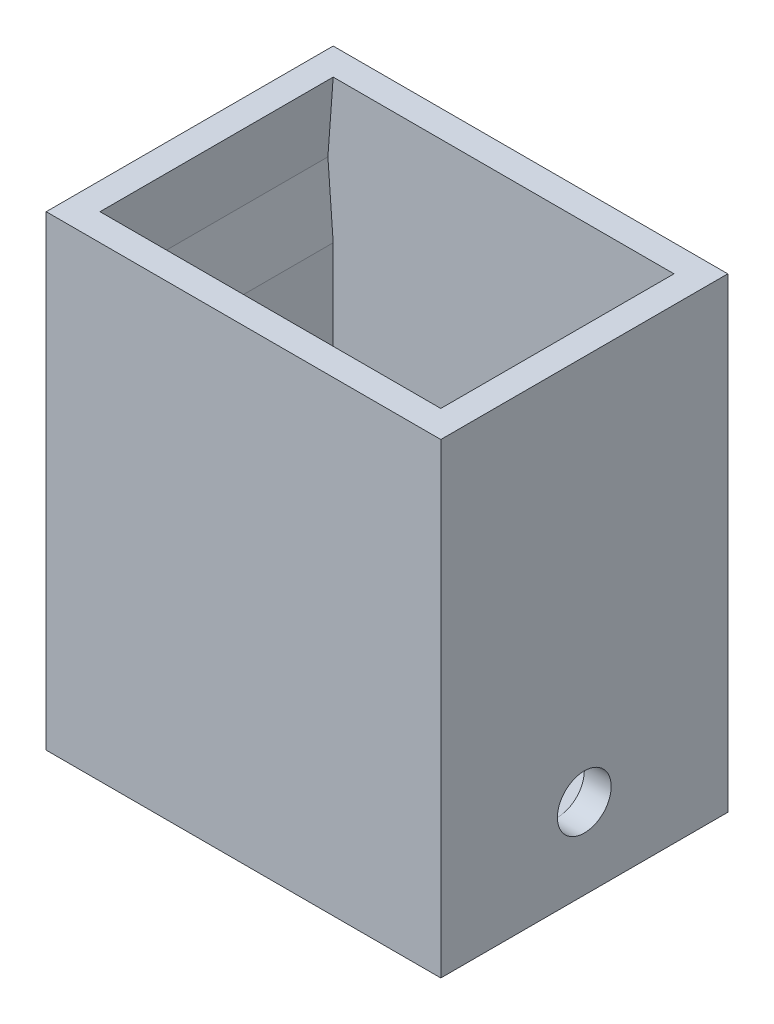
from build123d import *

# Parameters (mm, degrees)
SKETCH_1_W          = 22
SKETCH_1_H          = 16
SKETCH_1_W_2        = 19
SKETCH_1_H_2        = 13
EXTRUDE_1_DEPTH     = 23
SKETCH_2_W          = 22
SKETCH_2_H          = 16
EXTRUDE_2_DEPTH     = 3
SKETCH_3_R          = 1.25
CUT_EXTRUDE_1_DEPTH = 3
CHAMFER_1_SIZE      = 2
SKETCH_4_R          = 1.5
CUT_EXTRUDE_2_DEPTH = 28
CUT_EXTRUDE_3_DEPTH = 13


with BuildPart() as part:
    # Эскиз1 → Бобышка-Вытянуть1 (new body)
    with BuildSketch(Plane(origin=(0, 0, 0), x_dir=(1, 0, 0), z_dir=(0, 1, 0))):
        with Locations((-0.249343832, 2.073490814)):
            Rectangle(SKETCH_1_W, SKETCH_1_H)
        with Locations((-0.249343832, 2.073490814)):
            Rectangle(SKETCH_1_W_2, SKETCH_1_H_2, mode=Mode.SUBTRACT)
    extrude(amount=EXTRUDE_1_DEPTH)

    # Эскиз2 → Бобышка-Вытянуть2 (add)
    with BuildSketch(Plane.XZ):
        with Locations((-0.249343832, -2.073490814)):
            Rectangle(SKETCH_2_W, SKETCH_2_H)
    extrude(amount=EXTRUDE_2_DEPTH)

    # Эскиз3 → Вырез-Вытянуть1 (cut)
    with BuildSketch(Plane(origin=(0, 0, 0), x_dir=(1, 0, 0), z_dir=(0, 1, 0))):
        with Locations((-0.249343832, 2.073490814)):
            Circle(SKETCH_3_R)
    extrude(amount=-CUT_EXTRUDE_1_DEPTH, mode=Mode.SUBTRACT)

    # Фаска1
    chamfer_1_edges = [part.edges().sort_by_distance(p)[0] for p in [
        (-1.499343832, 0, -2.073490814),
    ]]
    chamfer(chamfer_1_edges, length=CHAMFER_1_SIZE)

    # Эскиз4 → Вырез-Вытянуть2 (cut)
    with BuildSketch(Plane(origin=(10.750656168, 0, 0), x_dir=(0, 0, -1), z_dir=(1, 0, 0))):
        with Locations((2.073490814, 1.5)):
            Circle(SKETCH_4_R)
    extrude(amount=-CUT_EXTRUDE_2_DEPTH, mode=Mode.SUBTRACT)

    # Эскиз5 → Вырез-Вытянуть3 (cut)
    with BuildSketch(Plane.XY.offset(-8.573490814)):
        Polygon((9.250656168, 23), (9.54509952, 19), (9.250656168, 15), align=None)
        Polygon((-10.043787184, 19), (-9.749343832, 15), (-9.749343832, 23), align=None)
    extrude(amount=CUT_EXTRUDE_3_DEPTH, mode=Mode.SUBTRACT)


solid = part.part
